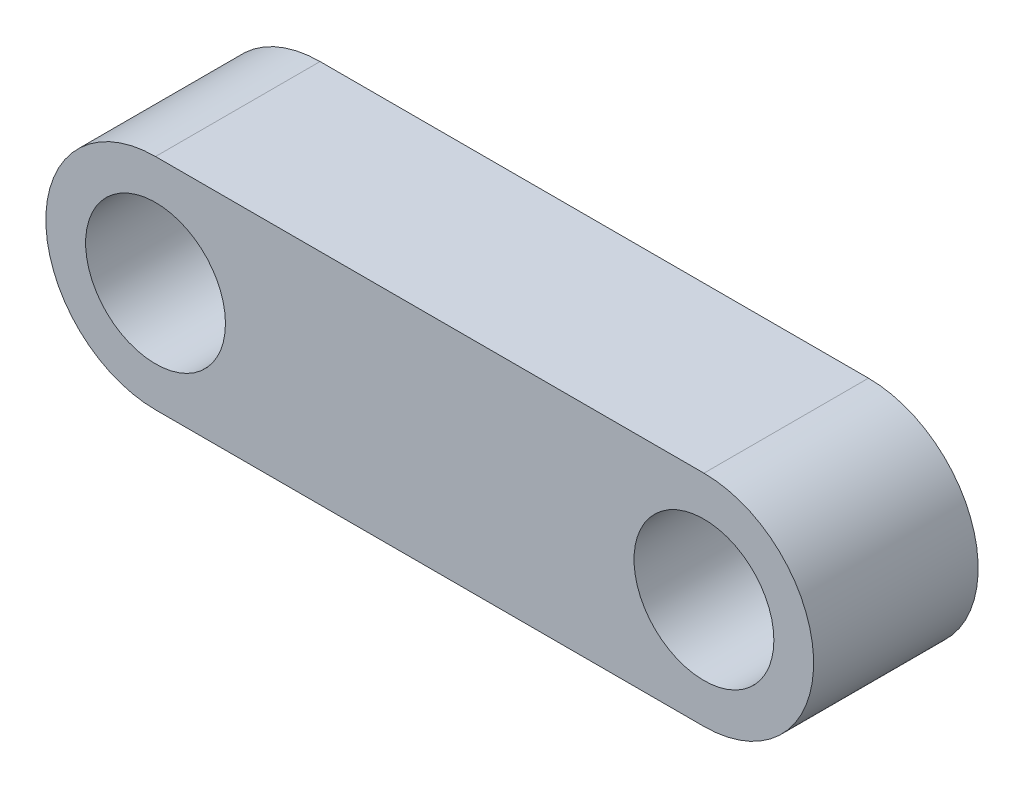
from build123d import *

# Parameters (mm, degrees)
SKETCH_1_R      = 2.55
EXTRUDE_1_DEPTH = 6


with BuildPart() as part:
    # Эскиз1 → Бобышка-Вытянуть1 (new body)
    with BuildSketch(Plane.XY):
        with BuildLine():
            Line((10, -4), (5, -4))
            Line((5, -4), (-10, -4))
            ThreePointArc((-10, -4), (-14, 0), (-10, 4))
            Line((-10, 4), (10, 4))
            ThreePointArc((10, 4), (14, 0), (10, -4))
        make_face()
        with Locations((10, 0)):
            Circle(SKETCH_1_R, mode=Mode.SUBTRACT)
        with Locations((-10, 0)):
            Circle(SKETCH_1_R, mode=Mode.SUBTRACT)
    extrude(amount=EXTRUDE_1_DEPTH)


solid = part.part
